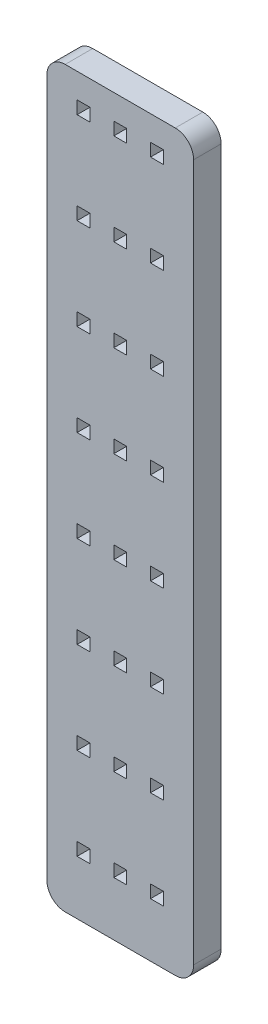
from build123d import *

# Parameters (mm, degrees)
SKETCH1_W           = 8
SKETCH1_H           = 5
BOSS_EXTRUDE1_DEPTH = 1.5
SKETCH2_W           = 0.7
SKETCH2_H           = 0.7
CUT_EXTRUDE1_DEPTH  = 5.949747468
LPATTERN1_COUNT     = 8
LPATTERN1_PITCH     = 5
FILLET1_R           = 1


with BuildPart() as part:
    # Sketch1 → Boss-Extrude1 (new body)
    with BuildSketch(Plane.XY):
        Rectangle(SKETCH1_W, SKETCH1_H)
    extrude(amount=BOSS_EXTRUDE1_DEPTH)

    # Sketch2 → Cut-Extrude1 (cut, through all)
    with BuildSketch(Plane.XY.offset(1.5)):
        with Locations((-2, 0.8)):
            Rectangle(SKETCH2_W, SKETCH2_H)
        with Locations((0, 0.8)):
            Rectangle(SKETCH2_W, SKETCH2_H)
        with Locations((2, 0.8)):
            Rectangle(SKETCH2_W, SKETCH2_H)
    extrude(amount=-CUT_EXTRUDE1_DEPTH, mode=Mode.SUBTRACT)


with BuildPart() as lpattern1_1:
    # LPattern1: pattern copy
    add(part.part.moved(Location(Vector(0, -1, 0) * (1 * LPATTERN1_PITCH))))


with BuildPart() as lpattern1_2:
    # LPattern1: pattern copy
    add(part.part.moved(Location(Vector(0, -1, 0) * (2 * LPATTERN1_PITCH))))


with BuildPart() as lpattern1_3:
    # LPattern1: pattern copy
    add(part.part.moved(Location(Vector(0, -1, 0) * (3 * LPATTERN1_PITCH))))


with BuildPart() as lpattern1_4:
    # LPattern1: pattern copy
    add(part.part.moved(Location(Vector(0, -1, 0) * (4 * LPATTERN1_PITCH))))


with BuildPart() as lpattern1_5:
    # LPattern1: pattern copy
    add(part.part.moved(Location(Vector(0, -1, 0) * (5 * LPATTERN1_PITCH))))


with BuildPart() as lpattern1_6:
    # LPattern1: pattern copy
    add(part.part.moved(Location(Vector(0, -1, 0) * (6 * LPATTERN1_PITCH))))


with BuildPart() as lpattern1_7:
    # LPattern1: pattern copy
    add(part.part.moved(Location(Vector(0, -1, 0) * (7 * LPATTERN1_PITCH))))


with BuildPart() as part_1:
    add(part.part)

    # Combine1: union LPattern1_1, LPattern1_2, LPattern1_3, LPattern1_4, LPattern1_5, LPattern1_6, LPattern1_7
    add(lpattern1_1.part)
    add(lpattern1_2.part)
    add(lpattern1_3.part)
    add(lpattern1_4.part)
    add(lpattern1_5.part)
    add(lpattern1_6.part)
    add(lpattern1_7.part)

    # Fillet1
    fillet1_edges = [part_1.edges().sort_by_distance(p)[0] for p in [
        (-4, -37.5, 0.75),
        (4, -37.5, 0.75),
        (4, 2.5, 0.75),
        (-4, 2.5, 0.75),
    ]]
    fillet(fillet1_edges, radius=FILLET1_R)


solid = part_1.part
